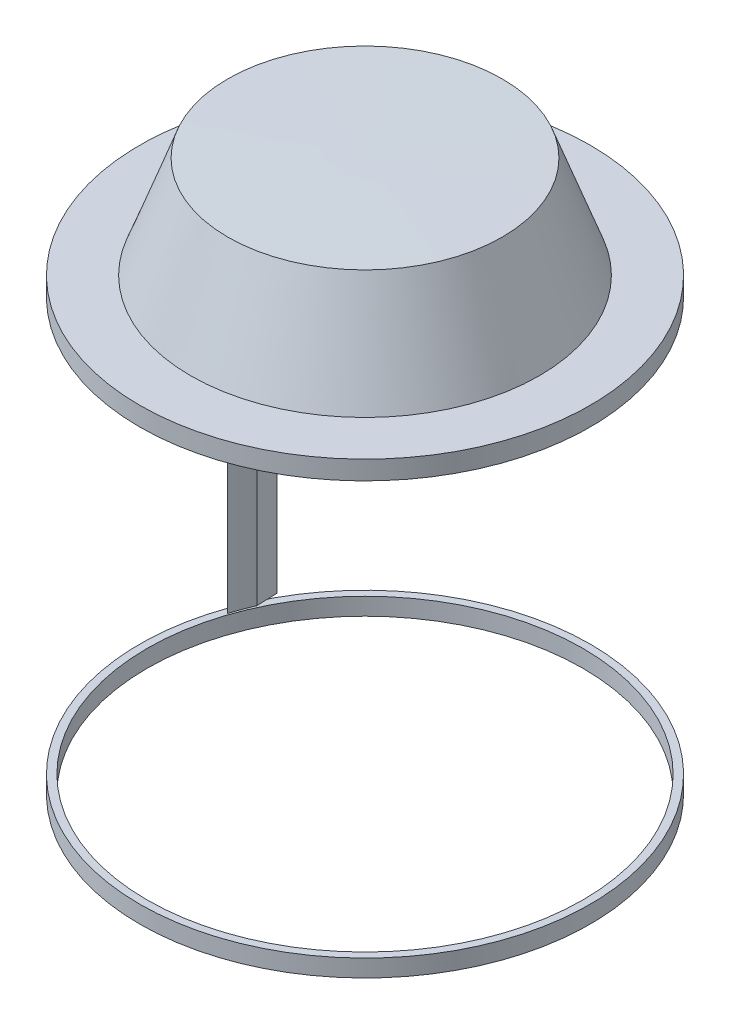
from build123d import *

# Parameters (mm, degrees)
CROQUIS3_W              = 2.5
CROQUIS3_H              = 93.200468797
CROQUIS3_H_2            = 93.221326365
SALIENTE_EXTRUIR1_DEPTH = 25
SALIENTE_EXTRUIR1_TAPER = 1
CROQUIS17_R             = 49.154267428
CORTAR_EXTRUIR1_DEPTH   = 98


with BuildPart() as part:
    # Croquis1 → Revolución1 (revolve)
    with BuildSketch(Plane.XY):
        Polygon((0, 38.800633525), (0, -62.573128225), (50.821461866, -62.573128225), (50.821461866, -58.674137389), (46.92247103, -58.674137389), (46.92247103, 34.547188976), (50.821461866, 34.547188976), (50.821461866, 38.800633525), align=None)
    revolve(axis=Axis((0, 38.800633525, 0), (0, -1, 0)))

    # Croquis3 → Saliente-Extruir1 (add)
    with BuildSketch(Plane.XY):
        with Locations((-45.646866178, -12.07390299)):
            Rectangle(CROQUIS3_W, CROQUIS3_H)
        with Locations((-40.124494984, -12.063474207)):
            Rectangle(CROQUIS3_W, CROQUIS3_H_2)
    extrude(amount=-SALIENTE_EXTRUIR1_DEPTH, taper=SALIENTE_EXTRUIR1_TAPER)

    # Croquis6 → Revolución3 (revolve)
    with BuildSketch(Plane.XY):
        Polygon((0, 61.973262814), (0, 38.800633525), (-39.309657337, 38.800633525), (-30.940786447, 61.707501888), align=None)
    revolve(axis=Axis((0, 61.973262814, 0), (0, -1, 0)))

    # Croquis17 → Cortar-Extruir1 (cut)
    with BuildSketch(Plane.XZ.offset(62.573128225)):
        Circle(CROQUIS17_R)
    extrude(amount=-CORTAR_EXTRUIR1_DEPTH, mode=Mode.SUBTRACT)


solid = part.part
